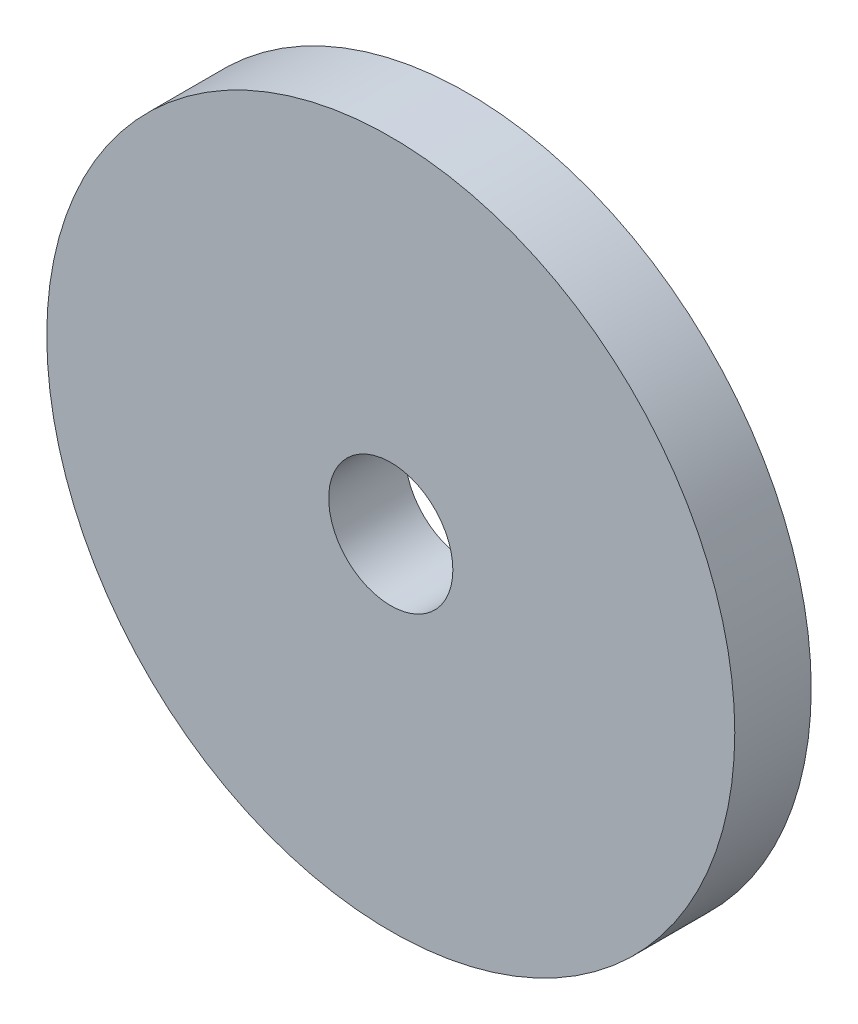
from build123d import *

# Parameters (mm, degrees)
SKETCH1_R      = 28.575
SKETCH1_R_2    = 5.1562
EXTRUDE1_DEPTH = 6.35


with BuildPart() as part:
    # Sketch1 → Extrude1 (new body)
    with BuildSketch(Plane.XY):
        Circle(SKETCH1_R)
        Circle(SKETCH1_R_2, mode=Mode.SUBTRACT)
    extrude(amount=EXTRUDE1_DEPTH)


solid = part.part
